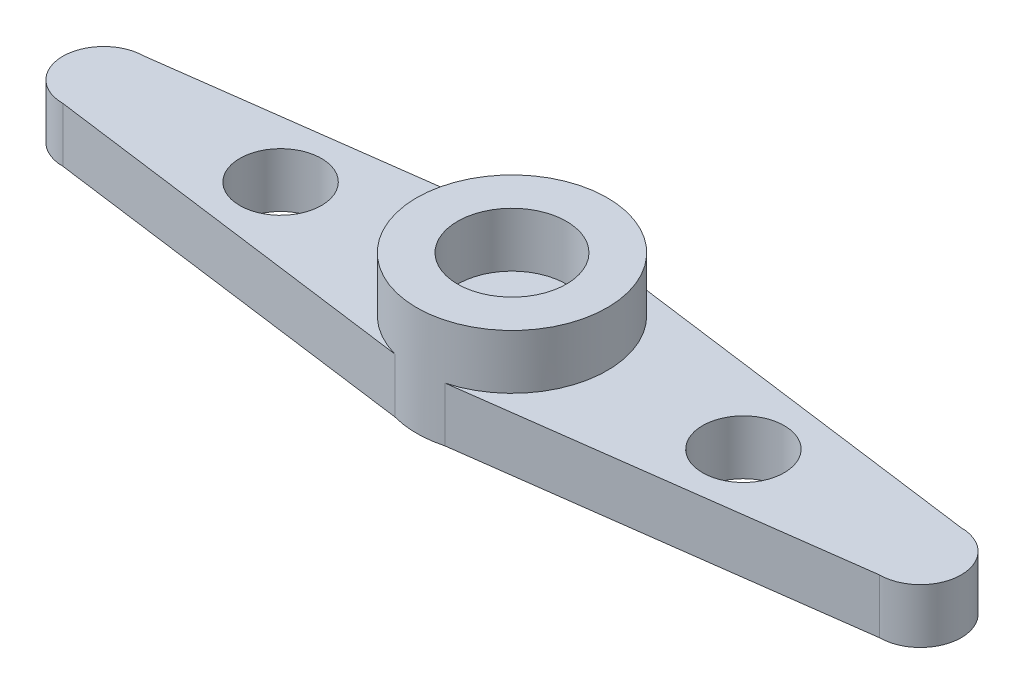
from build123d import *

# Parameters (mm, degrees)
ESQUISSE1_R             = 3.5
BOSS_EXTRU_1_DEPTH      = 4
ESQUISSE2_R             = 2
ENL_V_MAT_EXTRU_1_DEPTH = 2
BOSS_EXTRU_2_DEPTH      = 2
ESQUISSE4_R             = 1.5
BOSS_EXTRU_3_DEPTH      = 2
ESQUISSE5_R             = 1.5
ENL_V_MAT_EXTRU_2_DEPTH = 2


with BuildPart() as part:
    # Esquisse1 → Boss.-Extru.1 (new body)
    with BuildSketch(Plane(origin=(0, 0, 0), x_dir=(1, 0, 0), z_dir=(0, 1, 0))):
        Circle(ESQUISSE1_R)
    extrude(amount=BOSS_EXTRU_1_DEPTH)

    # Esquisse2 → Enlèv. mat.-Extru.1 (cut)
    with BuildSketch(Plane(origin=(0, 4, 0), x_dir=(1, 0, 0), z_dir=(0, 1, 0))):
        Circle(ESQUISSE2_R)
    extrude(amount=-ENL_V_MAT_EXTRU_1_DEPTH, mode=Mode.SUBTRACT)

    # Esquisse3 → Boss.-Extru.2 (add)
    with BuildSketch(Plane(origin=(0, 0, 0), x_dir=(1, 0, 0), z_dir=(0, 1, 0))):
        Polygon((0, 3.5), (15, 1.5), (15, -1.5), (0, -3.5), align=None)
    boss_extru_2 = extrude(amount=BOSS_EXTRU_2_DEPTH)

    # Esquisse4 → Boss.-Extru.3 (add)
    with BuildSketch(Plane(origin=(0, 2, 0), x_dir=(1, 0, 0), z_dir=(0, 1, 0))):
        with Locations((15, 0)):
            Circle(ESQUISSE4_R)
    boss_extru_3 = extrude(amount=-BOSS_EXTRU_3_DEPTH)

    # Symétrie1: Boss.-Extru.2, Boss.-Extru.3 across plane
    add(boss_extru_2.mirror(Plane(origin=(0, 0, 0), x_dir=(0, 0, 1), z_dir=(1, 0, 0))))
    add(boss_extru_3.mirror(Plane(origin=(0, 0, 0), x_dir=(0, 0, 1), z_dir=(1, 0, 0))))

    # Esquisse5 → Enlèv. mat.-Extru.2 (cut)
    with BuildSketch(Plane(origin=(0, 2, 0), x_dir=(1, 0, 0), z_dir=(0, 1, 0))):
        with Locations((-8.5, 0)):
            Circle(ESQUISSE5_R)
        with Locations((8.5, 0)):
            Circle(ESQUISSE5_R)
    extrude(amount=-ENL_V_MAT_EXTRU_2_DEPTH, mode=Mode.SUBTRACT)


solid = part.part
